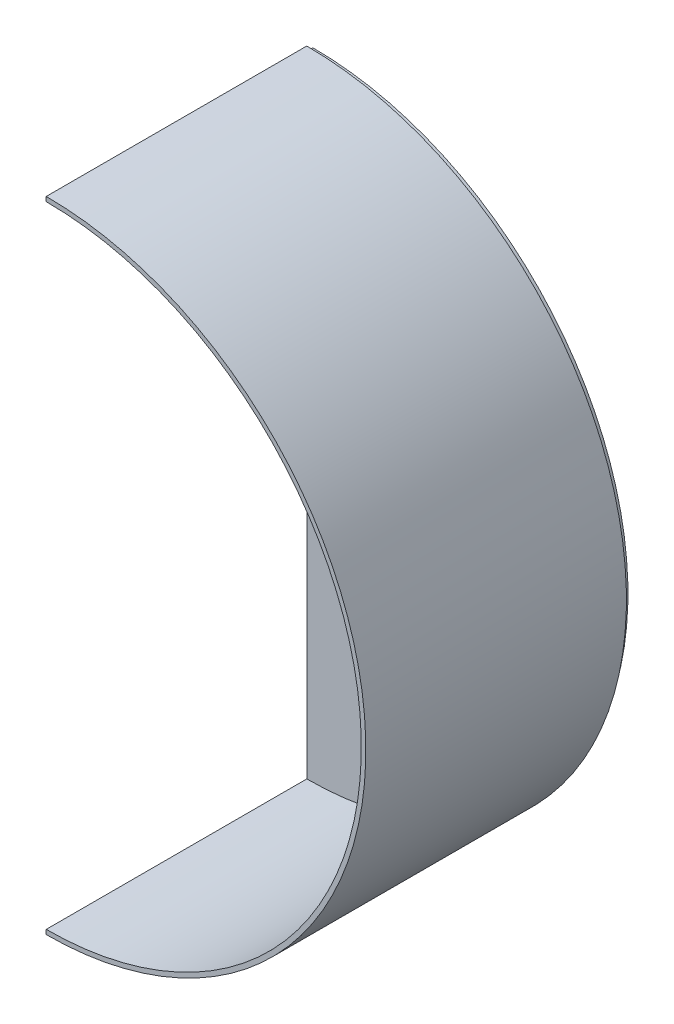
from build123d import *

# Parameters (mm, degrees)
BOSS_EXTRUDE2_DEPTH = 86
BOSS_EXTRUDE3_DEPTH = 2


with BuildPart() as part:
    # Sketch1 → Boss-Extrude2 (new body)
    with BuildSketch(Plane.XY):
        with BuildLine():
            Line((0, 0), (0, 1.5))
            ThreePointArc((0, 1.5), (104, 105.5), (0, 209.5))
            Line((0, 209.5), (0, 211))
            ThreePointArc((0, 211), (105.5, 105.5), (0, 0))
        make_face()
    extrude(amount=BOSS_EXTRUDE2_DEPTH)


with BuildPart() as body_2:
    # Sketch2 → Boss-Extrude3 (new body)
    with BuildSketch(Plane(origin=(0, 0, 0), x_dir=(-1, 0, 0), z_dir=(0, 0, -1))):
        with BuildLine():
            ThreePointArc((0, 209.5), (-104, 105.5), (0, 1.5))
            Line((0, 1.5), (0, 80))
            ThreePointArc((0, 80), (-25.5, 105.5), (0, 131))
            Line((0, 131), (0, 209.5))
        make_face()
        with BuildLine():
            ThreePointArc((-46.245759675, 88.398463435), (-36.745535683, 72.622979938), (-22.119655523, 61.433531111))
            Line((-22.119655523, 61.433531111), (-29.548996217, 26.752484238))
            ThreePointArc((-29.548996217, 26.752484238), (-58.477652485, 45.046062362), (-77.722279832, 73.350946611))
            Line((-77.722279832, 73.350946611), (-46.245759675, 88.398463435))
        make_face(mode=Mode.SUBTRACT)
        with BuildLine():
            ThreePointArc((-76.501203433, 140.455404294), (-58.459528985, 165.97146341), (-32.347829053, 183.13976025))
            Line((-32.347829053, 183.13976025), (-25.900416602, 147.455944282))
            ThreePointArc((-25.900416602, 147.455944282), (-36.848789706, 138.261250556), (-44.698922375, 126.311996043))
            Line((-44.698922375, 126.311996043), (-76.501203433, 140.455404294))
        make_face(mode=Mode.SUBTRACT)
    extrude(amount=BOSS_EXTRUDE3_DEPTH)


solid = Compound([part.part, body_2.part])
